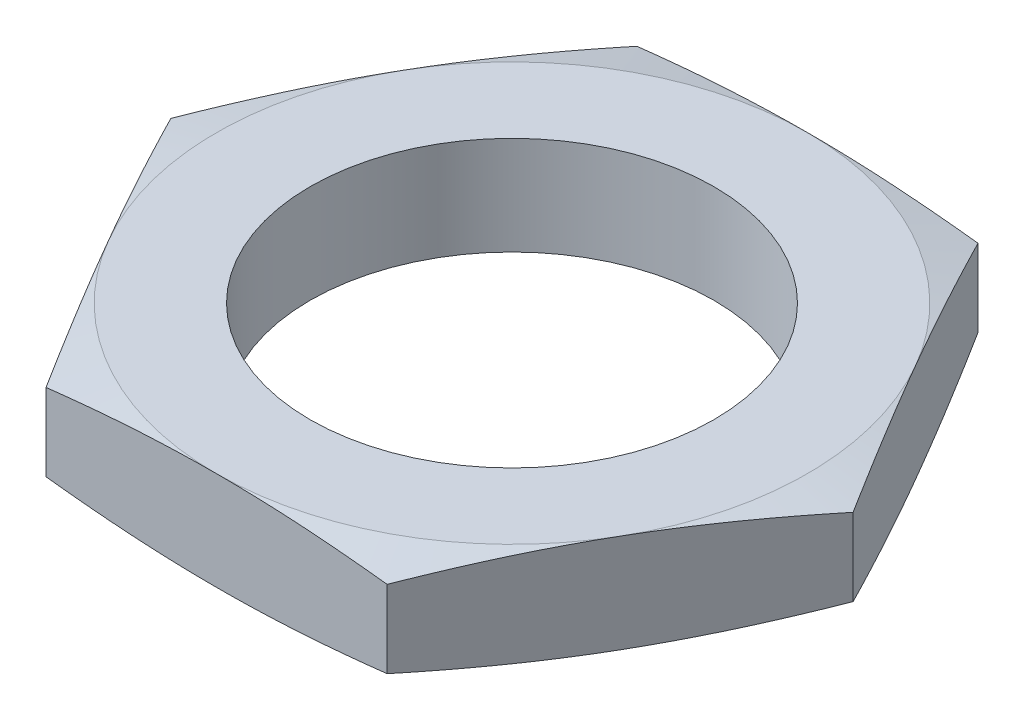
from build123d import *

# Parameters (mm, degrees)
SKETCH_1_R          = 10.25
EXTRUDE_1_DEPTH     = 5
SKETCH_2_OUTSIDE_W  = 97.84
SKETCH_2_OUTSIDE_H  = 93.198
SKETCH_2_OUTSIDE_R  = 15
CUT_EXTRUDE_1_DEPTH = 6
CUT_EXTRUDE_1_TAPER = 77
SKETCH_3_OUTSIDE_W  = 97.84
SKETCH_3_OUTSIDE_H  = 93.198
SKETCH_3_OUTSIDE_R  = 15
CUT_EXTRUDE_2_DEPTH = 6
CUT_EXTRUDE_2_TAPER = 77


with BuildPart() as part:
    # Эскиз1 → Бобышка-Вытянуть1 (new body)
    with BuildSketch(Plane(origin=(0, 0, 0), x_dir=(1, 0, 0), z_dir=(0, 1, 0))):
        Polygon((17.320508076, 0), (8.660254038, 15), (-8.660254038, 15), (-17.320508076, 0), (-8.660254038, -15), (8.660254038, -15), align=None)
        Circle(SKETCH_1_R, mode=Mode.SUBTRACT)
    extrude(amount=EXTRUDE_1_DEPTH)

    # Эскиз2 outside → Вырез-Вытянуть1 (cut, through all)
    with BuildSketch(Plane(origin=(0, 5, 0), x_dir=(1, 0, 0), z_dir=(0, 1, 0))):
        Rectangle(SKETCH_2_OUTSIDE_W, SKETCH_2_OUTSIDE_H)
        Circle(SKETCH_2_OUTSIDE_R, mode=Mode.SUBTRACT)
    extrude(amount=-CUT_EXTRUDE_1_DEPTH, taper=CUT_EXTRUDE_1_TAPER, mode=Mode.SUBTRACT)

    # Эскиз3 outside → Вырез-Вытянуть2 (cut, through all)
    with BuildSketch(Plane.XZ):
        Rectangle(SKETCH_3_OUTSIDE_W, SKETCH_3_OUTSIDE_H)
        Circle(SKETCH_3_OUTSIDE_R, mode=Mode.SUBTRACT)
    extrude(amount=-CUT_EXTRUDE_2_DEPTH, taper=CUT_EXTRUDE_2_TAPER, mode=Mode.SUBTRACT)


solid = part.part
